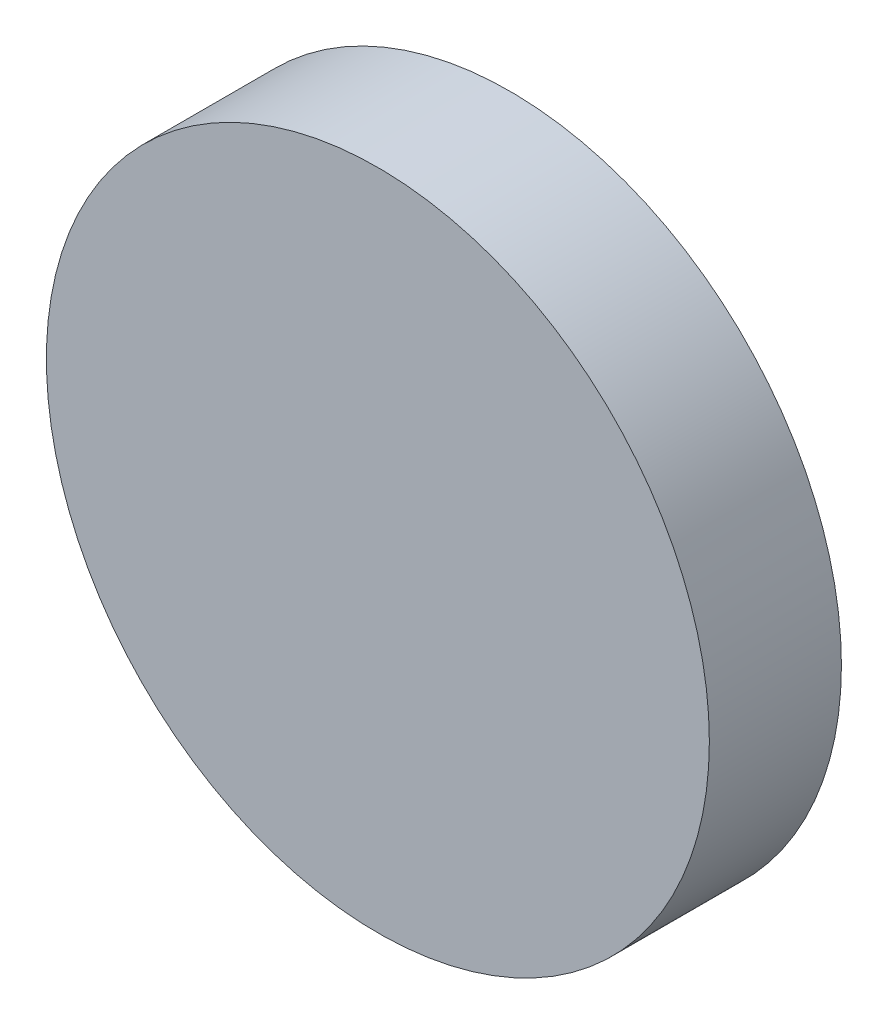
from build123d import *

# Parameters (mm, degrees)
SKETCH1_R           = 31.876749668
BOSS_EXTRUDE1_DEPTH = 12.7


with BuildPart() as part:
    # Sketch1 → Boss-Extrude1 (new body)
    with BuildSketch(Plane.XY):
        with Locations((-5.58082972, 1.511474716)):
            Circle(SKETCH1_R)
    extrude(amount=BOSS_EXTRUDE1_DEPTH)


solid = part.part
